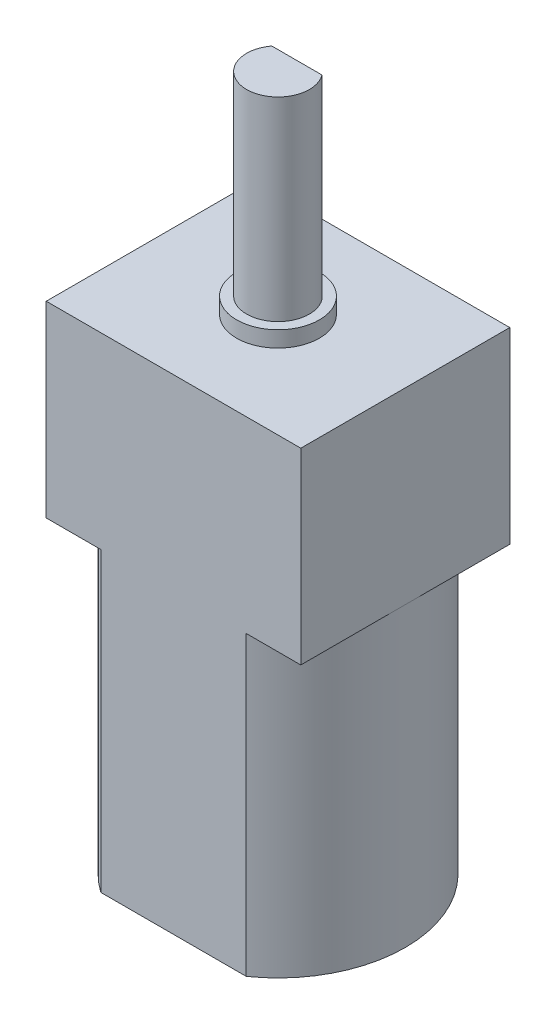
from build123d import *

# Parameters (mm, degrees)
BOSS_EXTRUDE1_DEPTH = 14
SKETCH3_W           = 12
SKETCH3_H           = 9.85
BOSS_EXTRUDE2_DEPTH = 8.85
SKETCH4_R           = 1.95
BOSS_EXTRUDE3_DEPTH = 0.75
BOSS_EXTRUDE4_DEPTH = 9.17
SKETCH6_R           = 2.47
BOSS_EXTRUDE5_DEPTH = 1.14


with BuildPart() as part:
    # Sketch2 → Boss-Extrude1 (new body)
    with BuildSketch(Plane(origin=(0, 0, 0), x_dir=(1, 0, 0), z_dir=(0, 1, 0))):
        with BuildLine():
            Line((-3.427006711, 4.925), (3.427006711, 4.925))
            ThreePointArc((3.427006711, 4.925), (6, 0), (3.427006711, -4.925))
            Line((3.427006711, -4.925), (-3.427006711, -4.925))
            ThreePointArc((-3.427006711, -4.925), (-6, 0), (-3.427006711, 4.925))
        make_face()
    extrude(amount=BOSS_EXTRUDE1_DEPTH)

    # Sketch3 → Boss-Extrude2 (add)
    with BuildSketch(Plane(origin=(0, 14, 0), x_dir=(1, 0, 0), z_dir=(0, 1, 0))):
        Rectangle(SKETCH3_W, SKETCH3_H)
    extrude(amount=BOSS_EXTRUDE2_DEPTH)

    # Sketch4 → Boss-Extrude3 (add)
    with BuildSketch(Plane(origin=(0, 22.85, 0), x_dir=(1, 0, 0), z_dir=(0, 1, 0))):
        Circle(SKETCH4_R)
    extrude(amount=BOSS_EXTRUDE3_DEPTH)

    # Sketch5 → Boss-Extrude4 (add)
    with BuildSketch(Plane(origin=(0, 23.6, 0), x_dir=(1, 0, 0), z_dir=(0, 1, 0))):
        with BuildLine():
            Line((-1.182497357, 0.89), (1.182497357, 0.89))
            ThreePointArc((1.182497357, 0.89), (0, -1.48), (-1.182497357, 0.89))
        make_face()
    extrude(amount=BOSS_EXTRUDE4_DEPTH)

    # Sketch6 → Boss-Extrude5 (add)
    with BuildSketch(Plane.XZ):
        Circle(SKETCH6_R)
    extrude(amount=BOSS_EXTRUDE5_DEPTH)


solid = part.part
